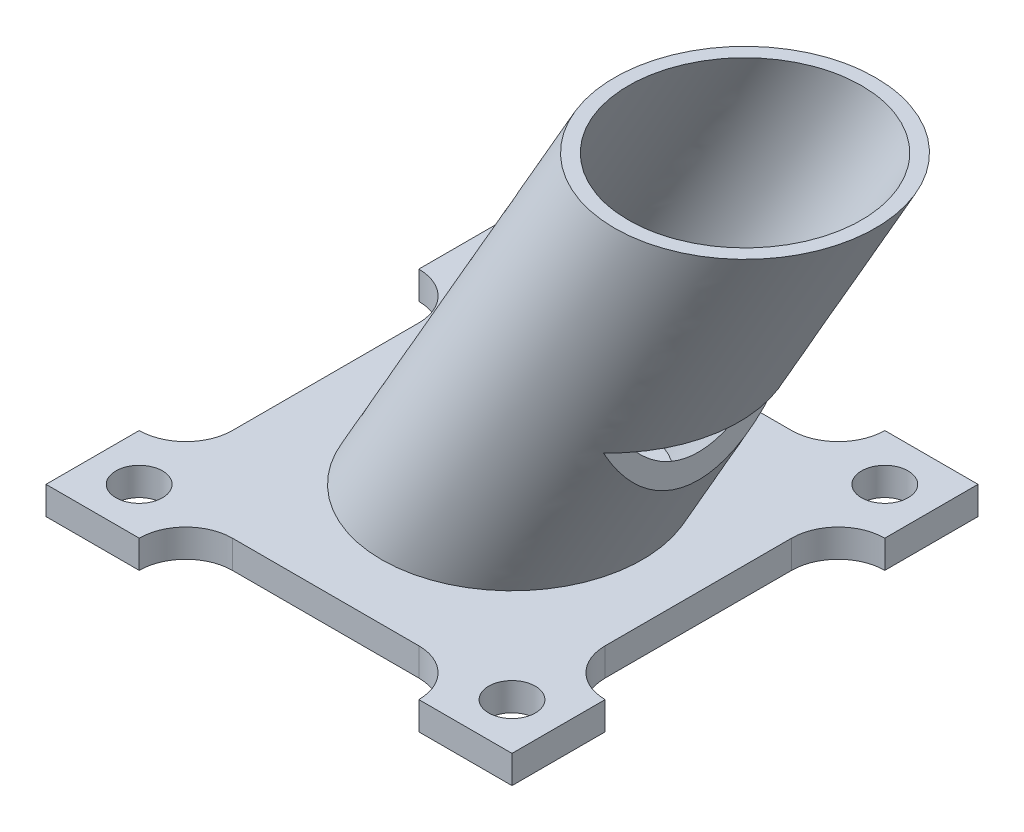
from build123d import *

# Parameters (mm, degrees)
SKETCH1_W           = 50
SKETCH1_H           = 50
BOSS_EXTRUDE1_DEPTH = 3
SKETCH3_R           = 14
SKETCH3_R_2         = 12.5
SKETCH4_R           = 2.5
CUT_EXTRUDE13_DEPTH = 3
SKETCH8_R           = 2.5
CUT_EXTRUDE20_DEPTH = 3
CUT_EXTRUDE22_DEPTH = 21
CIRPATTERN4_COUNT   = 4


with BuildPart() as part:
    # Sketch1 → Boss-Extrude1 (new body)
    with BuildSketch(Plane(origin=(0, 0, 0), x_dir=(1, 0, 0), z_dir=(0, 1, 0))):
        Rectangle(SKETCH1_W, SKETCH1_H)
    extrude(amount=BOSS_EXTRUDE1_DEPTH)

    # Sweep1: sweep along a path in Sketch2
    with BuildLine(Plane.XY) as sweep1_path:
        Line((0, 3), (25, 46.301270189))
    # Sketch3 → Sweep1 (sweep)
    with BuildSketch(Plane(origin=(0, 3, 0), x_dir=(1, 0, 0), z_dir=(0, 1, 0))):
        Circle(SKETCH3_R)
        Circle(SKETCH3_R_2, mode=Mode.SUBTRACT)
    sweep(path=sweep1_path.line)

    # Sketch4 → Cut-Extrude13 (cut)
    with BuildSketch(Plane(origin=(0, 0, 0), x_dir=(1, 0, 0), z_dir=(0, 1, 0))):
        with Locations((-20, 20)):
            Circle(SKETCH4_R)
    cut_extrude13 = extrude(amount=CUT_EXTRUDE13_DEPTH, mode=Mode.SUBTRACT)

    # Sketch8 → Cut-Extrude20 (cut)
    with BuildSketch(Plane(origin=(0, 0, 0), x_dir=(1, 0, 0), z_dir=(0, 1, 0))):
        with Locations((20, 20)):
            Circle(SKETCH8_R)
    cut_extrude20 = extrude(amount=CUT_EXTRUDE20_DEPTH, mode=Mode.SUBTRACT)

    # Mirror1: Cut-Extrude20 across plane
    add(cut_extrude20.mirror(Plane.XY), mode=Mode.SUBTRACT)

    # Mirror2: Cut-Extrude13 across plane
    add(cut_extrude13.mirror(Plane.XY), mode=Mode.SUBTRACT)

    # Sketch9 → Cut-Extrude22 (cut)
    with BuildSketch(Plane(origin=(0, 0, 0), x_dir=(1, 0, 0), z_dir=(0, 1, 0))):
        with BuildLine():
            Line((-10, 30), (10, 30))
            ThreePointArc((10, 30), (15, 25), (10, 20))
            Line((10, 20), (-10, 20))
            ThreePointArc((-10, 20), (-15, 25), (-10, 30))
        make_face()
    cut_extrude22 = extrude(amount=CUT_EXTRUDE22_DEPTH, mode=Mode.SUBTRACT)

    # CirPattern4: Cut-Extrude22 ×4 about axis
    cirpattern4_axis = Axis((0, 17.053416503, 0), (0, 1, 0))
    for i in range(1, CIRPATTERN4_COUNT):
        add(cut_extrude22.rotate(cirpattern4_axis, i * 360 / CIRPATTERN4_COUNT), mode=Mode.SUBTRACT)


solid = part.part
